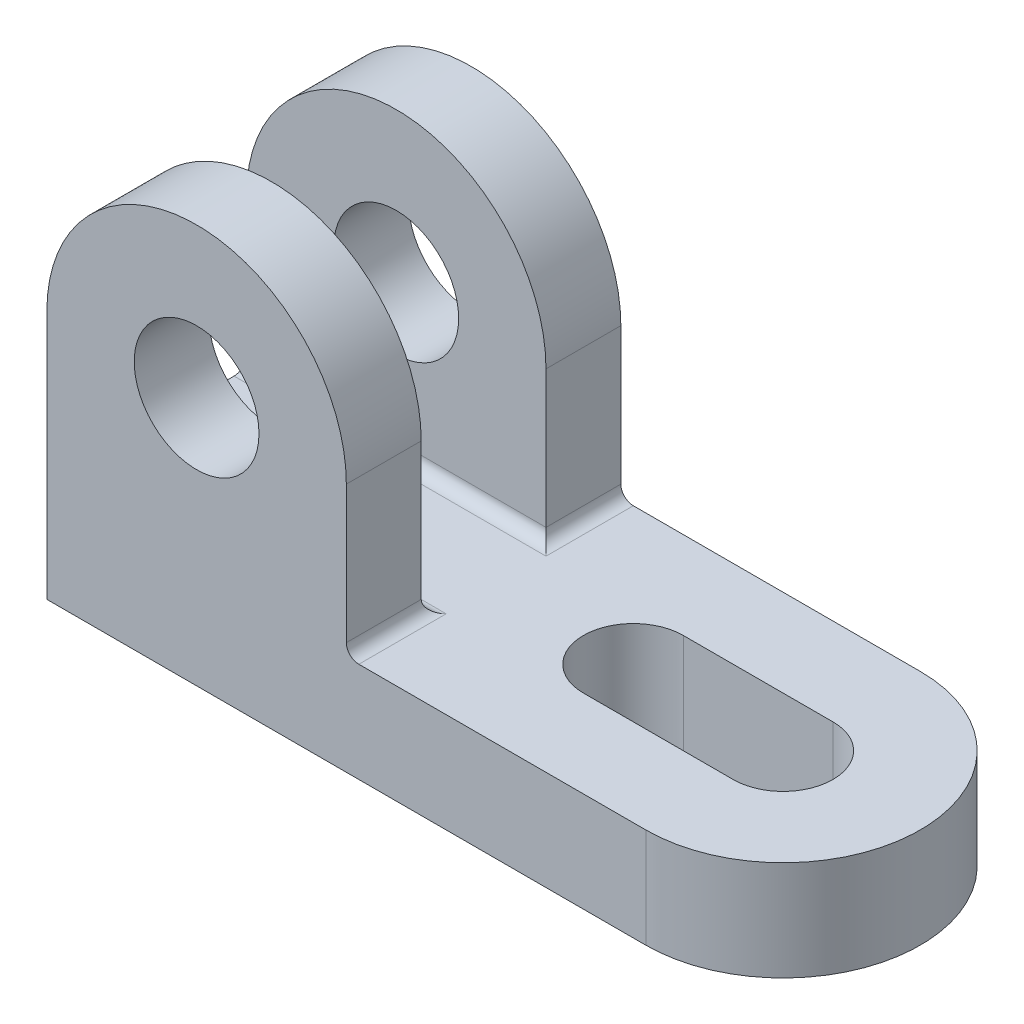
from build123d import *

# Parameters (mm, degrees)
BOSS_EXTRUDE2_DEPTH = 16
SKETCH2_R           = 10
BOSS_EXTRUDE3_DEPTH = 44
SKETCH4_W           = 20
SKETCH4_H           = 48
CUT_EXTRUDE1_DEPTH  = 49
FILLET1_R           = 2


with BuildPart() as part:
    # Sketch1 → Boss-Extrude2 (new body)
    with BuildSketch(Plane(origin=(0, 0, 0), x_dir=(1, 0, 0), z_dir=(0, 1, 0))):
        with BuildLine():
            Line((0, 0), (96, 0))
            ThreePointArc((96, 0), (118, 22), (96, 44))
            Line((96, 44), (0, 44))
            Line((0, 44), (0, 0))
        make_face()
        with BuildLine():
            Line((96, 14), (72, 14))
            ThreePointArc((72, 14), (64, 22), (72, 30))
            Line((72, 30), (96, 30))
            ThreePointArc((96, 30), (104, 22), (96, 14))
        make_face(mode=Mode.SUBTRACT)
    extrude(amount=BOSS_EXTRUDE2_DEPTH)

    # Sketch2 → Boss-Extrude3 (add)
    with BuildSketch(Plane.XY):
        with BuildLine():
            Line((0, 16), (48, 16))
            Line((48, 16), (48, 40))
            ThreePointArc((48, 40), (24, 64), (0, 40))
            Line((0, 40), (0, 16))
        make_face()
        with Locations((24, 40)):
            Circle(SKETCH2_R, mode=Mode.SUBTRACT)
    extrude(amount=-BOSS_EXTRUDE3_DEPTH)

    # Sketch4 → Cut-Extrude1 (cut, through all)
    with BuildSketch(Plane(origin=(48, 0, 0), x_dir=(0, 0, -1), z_dir=(1, 0, 0))):
        with Locations((22, 40)):
            Rectangle(SKETCH4_W, SKETCH4_H)
    extrude(amount=-CUT_EXTRUDE1_DEPTH, mode=Mode.SUBTRACT)

    # Fillet1
    fillet1_edges = [part.edges().sort_by_distance(p)[0] for p in [
        (48, 16, -38),
        (48, 16, -6),
        (24, 16, -12),
        (24, 16, -32),
    ]]
    fillet(fillet1_edges, radius=FILLET1_R)


solid = part.part
